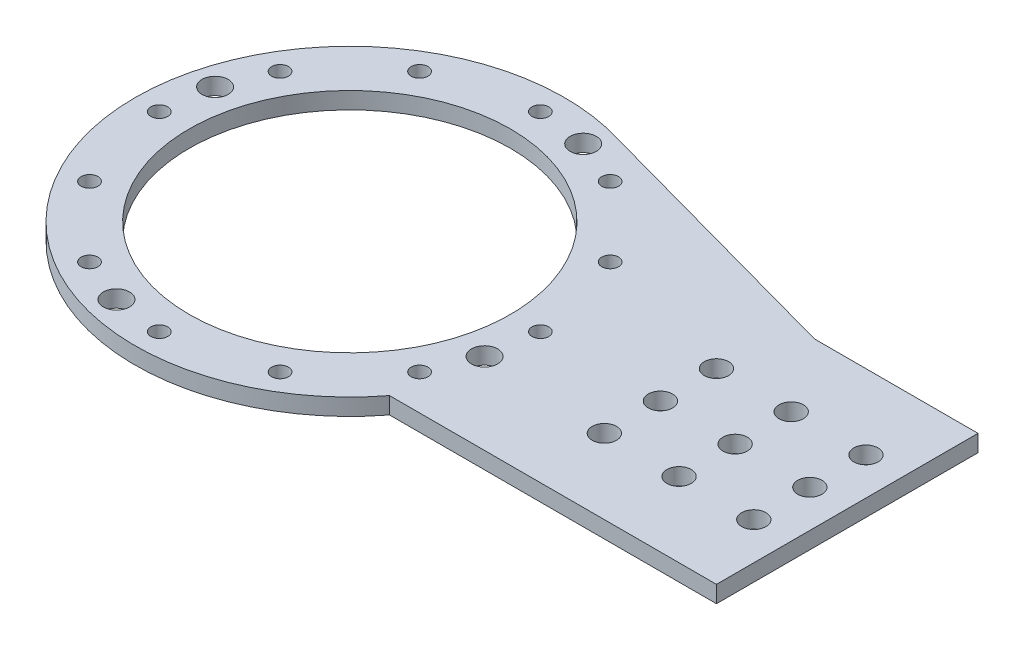
from build123d import *

# Parameters (mm, degrees)
SKETCH1_R           = 57.5
BOSS_EXTRUDE1_DEPTH = 4.5
SKETCH2_W           = 140
SKETCH2_H           = 70
BOSS_EXTRUDE2_DEPTH = 4.5
BOSS_EXTRUDE3_DEPTH = 4.5
SKETCH4_R           = 43
CUT_EXTRUDE1_DEPTH  = 5.5
SKETCH7_R           = 3.25
CUT_EXTRUDE8_DEPTH  = 5.5
LPATTERN1_COUNT     = 3
LPATTERN1_PITCH     = 20
CUT_EXTRUDE5_START  = -1
SKETCH5_R           = 2.25
CUT_EXTRUDE5_DEPTH  = 6.5
CIRPATTERN1_COUNT   = 12
SKETCH12_R          = 3.5
CUT_EXTRUDE17_DEPTH = 5.5
CIRPATTERN2_COUNT   = 4
SKETCH13_R          = 3.25
CUT_EXTRUDE18_DEPTH = 10
LPATTERN2_COUNT     = 3
LPATTERN2_PITCH     = 20


with BuildPart() as part:
    # Sketch1 → Boss-Extrude1 (new body)
    with BuildSketch(Plane(origin=(0, 0, 0), x_dir=(1, 0, 0), z_dir=(0, 1, 0))):
        Circle(SKETCH1_R)
    extrude(amount=BOSS_EXTRUDE1_DEPTH)

    # Sketch2 → Boss-Extrude2 (add)
    with BuildSketch(Plane(origin=(0, 0, 0), x_dir=(1, 0, 0), z_dir=(0, 1, 0))):
        with Locations((63.125798099, 0)):
            Rectangle(SKETCH2_W, SKETCH2_H)
    extrude(amount=BOSS_EXTRUDE2_DEPTH)

    # Sketch3 → Boss-Extrude3 (add)
    with BuildSketch(Plane(origin=(0, 0, 0), x_dir=(1, 0, 0), z_dir=(0, 1, 0))):
        Polygon((89.373258538, 35), (13.76852627, 55.827212758), (13.76852627, 13.558751548), align=None)
    extrude(amount=BOSS_EXTRUDE3_DEPTH)

    # Sketch4 → Cut-Extrude1 (cut, through all)
    with BuildSketch(Plane(origin=(0, 4.5, 0), x_dir=(1, 0, 0), z_dir=(0, 1, 0))):
        Circle(SKETCH4_R)
    extrude(amount=-CUT_EXTRUDE1_DEPTH, mode=Mode.SUBTRACT)

    # Sketch7 → Cut-Extrude8 (cut, through all)
    with BuildSketch(Plane(origin=(0, 4.5, 0), x_dir=(1, 0, 0), z_dir=(0, 1, 0))):
        with Locations((123.125798099, 15)):
            Circle(SKETCH7_R)
        with Locations((123.125798099, -15)):
            Circle(SKETCH7_R)
    cut_extrude8 = extrude(amount=-CUT_EXTRUDE8_DEPTH, mode=Mode.SUBTRACT)

    # LPattern1: Cut-Extrude8 ×3
    with Locations(*[(-i * LPATTERN1_PITCH, 0, 0) for i in range(1, LPATTERN1_COUNT)]):
        add(cut_extrude8, mode=Mode.SUBTRACT)

    # Sketch5 → Cut-Extrude5 (cut)
    with BuildSketch(Plane(origin=(0, 0, 0), x_dir=(1, 0, 0), z_dir=(0, 1, 0)).offset(CUT_EXTRUDE5_START)):
        with Locations((-51, 0)):
            Circle(SKETCH5_R)
    cut_extrude5 = extrude(amount=CUT_EXTRUDE5_DEPTH, mode=Mode.SUBTRACT)

    # CirPattern1: Cut-Extrude5 ×12 about axis
    cirpattern1_axis = Axis((0, 0, 0), (0, 1, 0))
    for i in range(1, CIRPATTERN1_COUNT):
        add(cut_extrude5.rotate(cirpattern1_axis, i * 360 / CIRPATTERN1_COUNT), mode=Mode.SUBTRACT)

    # Sketch12 → Cut-Extrude17 (cut, through all)
    with BuildSketch(Plane(origin=(0, 4.5, 0), x_dir=(1, 0, 0), z_dir=(0, 1, 0))):
        with Locations((-49.262217141, 13.1997713)):
            Circle(SKETCH12_R)
    cut_extrude17 = extrude(amount=-CUT_EXTRUDE17_DEPTH, mode=Mode.SUBTRACT)

    # CirPattern2: Cut-Extrude17 ×4 about axis
    cirpattern2_axis = Axis((0, 0, 0), (0, 1, 0))
    for i in range(1, CIRPATTERN2_COUNT):
        add(cut_extrude17.rotate(cirpattern2_axis, i * 360 / CIRPATTERN2_COUNT), mode=Mode.SUBTRACT)

    # Sketch13 → Cut-Extrude18 (cut)
    with BuildSketch(Plane(origin=(0, 4.5, 0), x_dir=(1, 0, 0), z_dir=(0, 1, 0))):
        with Locations((123.125798099, 0)):
            Circle(SKETCH13_R)
    cut_extrude18 = extrude(amount=-CUT_EXTRUDE18_DEPTH, mode=Mode.SUBTRACT)

    # LPattern2: Cut-Extrude18 ×3
    with Locations(*[(-i * LPATTERN2_PITCH, 0, 0) for i in range(1, LPATTERN2_COUNT)]):
        add(cut_extrude18, mode=Mode.SUBTRACT)


solid = part.part
